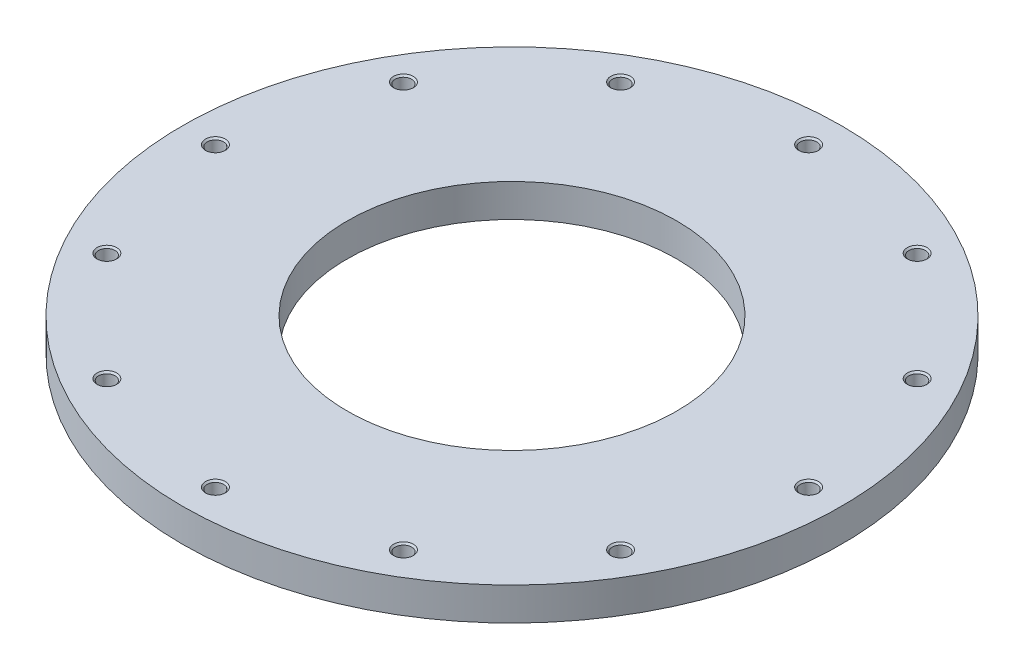
from build123d import *

# Parameters (mm, degrees)
SKETCH1_W                             = 63.5
SKETCH1_H                             = 12.7
F_1_4_0_25_DIAMETER_HOLE1_D           = 6.35
F_1_4_0_25_DIAMETER_HOLE1_CSINK_D     = 7.62
F_1_4_0_25_DIAMETER_HOLE1_CSINK_ANGLE = 90
CIRPATTERN1_COUNT                     = 12


with BuildPart() as part:
    # Sketch1 → Revolve1 (revolve)
    with BuildSketch(Plane.XY):
        with Locations((-95.25, -6.35)):
            Rectangle(SKETCH1_W, SKETCH1_H)
    revolve(axis=Axis((0, 0, 0), (0, 1, 0)))

    # 1/4 (0.25) Diameter Hole1 (through all)
    with Locations(Plane(origin=(114.3, 0, 0), x_dir=(0, 0, 1), z_dir=(0, 1, 0))):
        with Locations((0, 0)):
            f_1_4_0_25_diameter_hole1 = CounterSinkHole(F_1_4_0_25_DIAMETER_HOLE1_D / 2, F_1_4_0_25_DIAMETER_HOLE1_CSINK_D / 2, counter_sink_angle=F_1_4_0_25_DIAMETER_HOLE1_CSINK_ANGLE)

    # CirPattern1: 1/4 (0.25) Diameter Hole1 ×12 about axis
    cirpattern1_axis = Axis((0, 0, 0), (0, 1, 0))
    for i in range(1, CIRPATTERN1_COUNT):
        add(f_1_4_0_25_diameter_hole1.rotate(cirpattern1_axis, i * 360 / CIRPATTERN1_COUNT), mode=Mode.SUBTRACT)


solid = part.part
